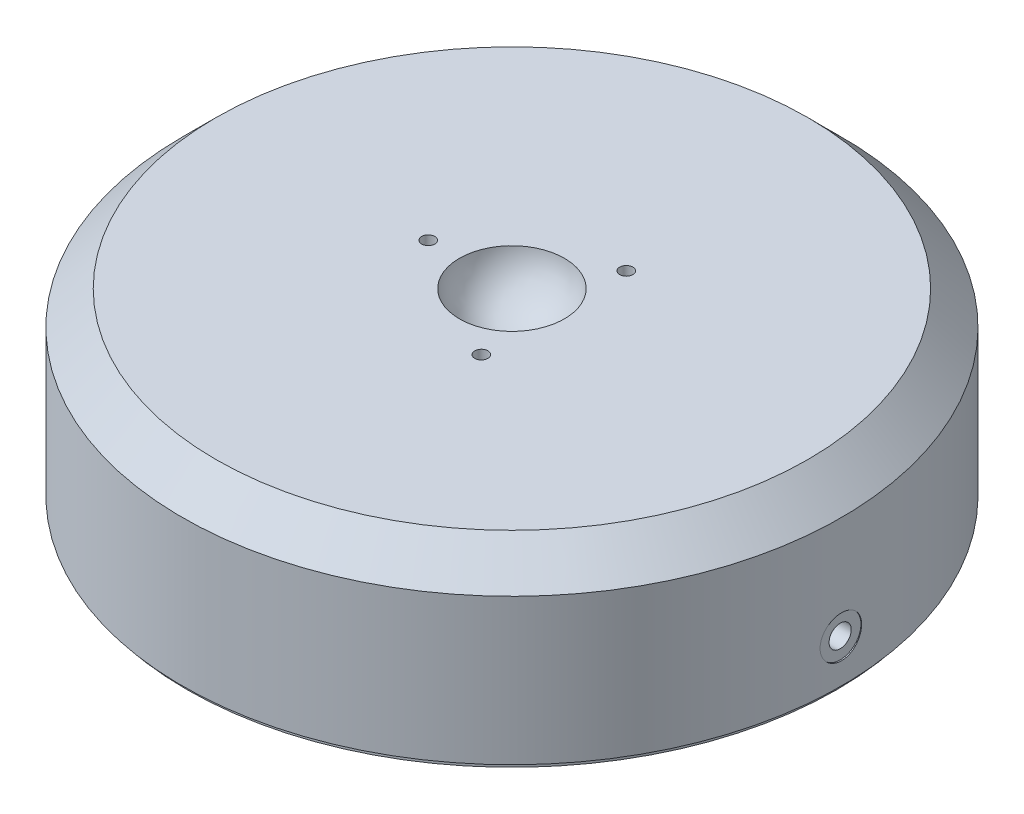
from build123d import *

# Parameters (mm, degrees)
M5X0_8_TAPPED_HOLE1_D                               = 4.2
M5X0_8_TAPPED_HOLE1_DEPTH                           = 46.99
M5X0_8_TAPPED_HOLE1_TIP                             = 1.2618073
CIRPATTERN1_COUNT                                   = 3
CBORE_FOR_00_BINDING_HEAD_MACHINE_SCREW_D           = 1.397
CBORE_FOR_00_BINDING_HEAD_MACHINE_SCREW_DEPTH       = 6.35
CBORE_FOR_00_BINDING_HEAD_MACHINE_SCREW_CBORE_D     = 7.874
CBORE_FOR_00_BINDING_HEAD_MACHINE_SCREW_CBORE_DEPTH = 0.254
CBORE_FOR_00_BINDING_HEAD_MACHINE_SCREW_TIP         = 0.419701142
SKETCH2_R                                           = 61.6585
EXTRUDE1_DEPTH                                      = 1.016


with BuildPart() as part:
    # Sketch1 → Revolve1 (revolve)
    with BuildSketch(Plane.XY, mode=Mode.PRIVATE) as revolve1_sk:
        with BuildLine():
            Line((0, 0), (62.4967, 0))
            Line((62.4967, 0), (62.4967, 27.6606))
            Line((62.4967, 27.6606), (56.1467, 34.0106))
            Line((56.1467, 34.0106), (9.955892816, 34.0106))
            ThreePointArc((9.955892816, 34.0106), (7.551444809, 28.459428687), (2.3876, 25.307987753))
            Line((2.3876, 25.307987753), (2.3876, 24.6126))
            Line((2.3876, 24.6126), (0, 24.6126))
            Line((0, 24.6126), (0, 0))
        make_face()
    revolve(revolve1_sk.sketch.rotate(Axis((0, 23.9776, 0), (0, -1, 0)), 180), axis=Axis((0, 23.9776, 0), (0, -1, 0)))  # turned: the seam where the file's is

    # M5x0.8 Tapped Hole1
    with Locations(Plane(origin=(62.4967, 8.0772, 0), x_dir=(0, 0, 1), z_dir=(1, 0, 0))):
        with Locations((0, 0)):
            Hole(M5X0_8_TAPPED_HOLE1_D / 2, depth=M5X0_8_TAPPED_HOLE1_DEPTH)
            with Locations((0, 0, -(M5X0_8_TAPPED_HOLE1_DEPTH + M5X0_8_TAPPED_HOLE1_TIP / 2))):  # 118° drill point
                Cone(0, M5X0_8_TAPPED_HOLE1_D / 2, M5X0_8_TAPPED_HOLE1_TIP, mode=Mode.SUBTRACT)

    # Sketch5 → M3x0.5 Tapped Hole1 (revolve, cut)
    with BuildSketch(Plane(origin=(-15.875, 34.0106, 0), x_dir=(0, 0, 1), z_dir=(1, 0, 0))):
        Polygon((0, 0), (0, 10.403075774), (1.25, 9.652), (1.25, 0), align=None)
    m3x0_5_tapped_hole1 = revolve(axis=Axis((-15.875, 40.3606, 0), (0, -1, 0)), mode=Mode.SUBTRACT)

    # CirPattern1: M3x0.5 Tapped Hole1 ×3 about axis
    cirpattern1_axis = Axis((0, 0, 0), (0, 1, 0))
    for i in range(1, CIRPATTERN1_COUNT):
        add(m3x0_5_tapped_hole1.rotate(cirpattern1_axis, i * 360 / CIRPATTERN1_COUNT), mode=Mode.SUBTRACT)

    # CBORE for #00 Binding Head Machine Screw1
    with Locations(Plane(origin=(62.4967, 8.0772, 0), x_dir=(0, 0, 1), z_dir=(1, 0, 0))):
        with Locations((0, 0)):
            CounterBoreHole(CBORE_FOR_00_BINDING_HEAD_MACHINE_SCREW_D / 2, CBORE_FOR_00_BINDING_HEAD_MACHINE_SCREW_CBORE_D / 2, CBORE_FOR_00_BINDING_HEAD_MACHINE_SCREW_CBORE_DEPTH, depth=CBORE_FOR_00_BINDING_HEAD_MACHINE_SCREW_DEPTH)
            with Locations((0, 0, -(CBORE_FOR_00_BINDING_HEAD_MACHINE_SCREW_DEPTH + CBORE_FOR_00_BINDING_HEAD_MACHINE_SCREW_TIP / 2))):  # 118° drill point
                Cone(0, CBORE_FOR_00_BINDING_HEAD_MACHINE_SCREW_D / 2, CBORE_FOR_00_BINDING_HEAD_MACHINE_SCREW_TIP, mode=Mode.SUBTRACT)

    # Sketch2 → Extrude1 (add)
    with BuildSketch(Plane.XZ):
        with Locations(Location((0, 0, 0), (0, 0, 180))):  # turned: the seam where the file's is
            Circle(SKETCH2_R)
    extrude(amount=EXTRUDE1_DEPTH)


solid = part.part
